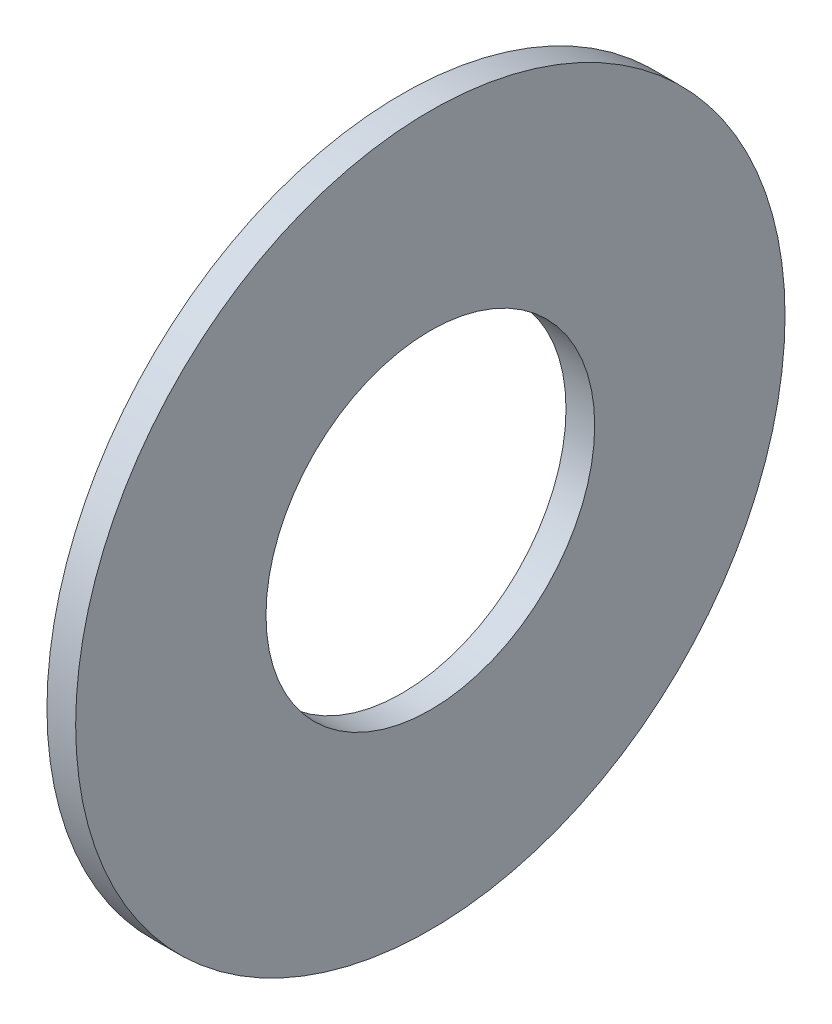
from build123d import *

# Parameters (mm, degrees)
SKETCH1_W = 4.572
SKETCH1_H = 30.3276


with BuildPart() as part:
    # Sketch1 → Base-Revolve (revolve)
    with BuildSketch(Plane.XY):
        with Locations((-2.286, 41.3512)):
            Rectangle(SKETCH1_W, SKETCH1_H)
    revolve(axis=Axis((-34.925, 0, 0), (1, 0, 0)))


solid = part.part
